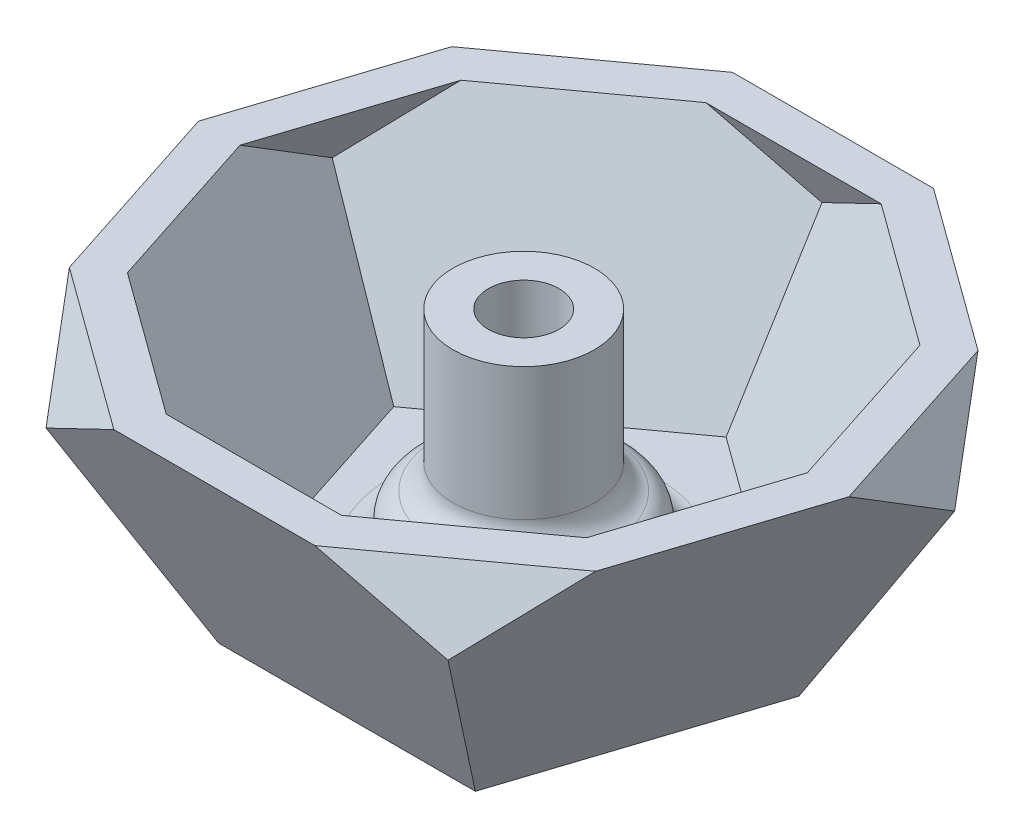
from build123d import *

# Parameters (mm, degrees)
BOSS_EXTRUDE1_DEPTH     = 30
BOSS_EXTRUDE1_TAPER     = -26.56505118
SKETCH3_OUTSIDE_W       = 108.076
SKETCH3_OUTSIDE_H       = 105.2
CUT_EXTRUDE1_DEPTH      = 30
CUT_EXTRUDE1_TAPER      = 26.56505118
SKETCH5_R               = 19.347524159
CUT_EXTRUDE2_DEPTH      = 25
SHELL1_T                = -2
SKETCH6_R               = 4
SKETCH6_R_2             = 2
BOSS_EXTRUDE2_DEPTH     = 13
SKETCH10_R              = 6
SKETCH10_R_2            = 4
BOSS_EXTRUDE4_DEPTH     = 3
FILLET5_R               = 1.5
CUT_EXTRUDE3_START      = -1
CUT_EXTRUDE3_DEPTH      = 2
CUT_EXTRUDE3_DEPTH_BACK = 2
FILLET6_R               = 1.5


with BuildPart() as part:
    # Sketch1 → Boss-Extrude1 (new body)
    with BuildSketch(Plane(origin=(0, 0, 0), x_dir=(1, 0, 0), z_dir=(0, 1, 0))):
        Polygon((0, 12.360679775), (-11.755705046, 3.819660113), (-7.26542528, -10), (7.26542528, -10), (11.755705046, 3.819660113), align=None)
    extrude(amount=BOSS_EXTRUDE1_DEPTH, taper=BOSS_EXTRUDE1_TAPER)

    # Sketch3 outside → Cut-Extrude1 (cut)
    with BuildSketch(Plane(origin=(0, 30, 0), x_dir=(1, 0, 0), z_dir=(0, 1, 0))):
        with Locations((0, 2.951)):
            Rectangle(SKETCH3_OUTSIDE_W, SKETCH3_OUTSIDE_H)
        Polygon((7.26542528, 10), (-7.26542528, 10), (-11.755705046, -3.819660113), (0, -12.360679775), (11.755705046, -3.819660113), align=None, mode=Mode.SUBTRACT)
    extrude(amount=-CUT_EXTRUDE1_DEPTH, taper=CUT_EXTRUDE1_TAPER, mode=Mode.SUBTRACT)

    # Sketch5 → Cut-Extrude2 (cut)
    with BuildSketch(Plane(origin=(0, 15, 0), x_dir=(1, 0, 0), z_dir=(0, 1, 0))):
        Circle(SKETCH5_R)
    extrude(amount=CUT_EXTRUDE2_DEPTH, mode=Mode.SUBTRACT)

    # Shell1
    shell1_openings = [part.faces().sort_by_distance(p)[0] for p in [
        (0, 15, 0),
    ]]
    offset(amount=SHELL1_T, openings=shell1_openings, kind=Kind.INTERSECTION)

    # Sketch6 → Boss-Extrude2 (add)
    with BuildSketch(Plane(origin=(0, 2, 0), x_dir=(1, 0, 0), z_dir=(0, 1, 0))):
        Circle(SKETCH6_R)
        Circle(SKETCH6_R_2, mode=Mode.SUBTRACT)
    extrude(amount=BOSS_EXTRUDE2_DEPTH)

    # Sketch12 → Loft1 section 0
    with BuildSketch(Plane(origin=(0, 3, 0), x_dir=(1, 0, 0), z_dir=(0, 1, 0))):
        Polygon((0, 11.450849719), (-10.890405242, 3.538507163), (-6.730640591, -9.263932023), (6.730640591, -9.263932023), (10.890405242, 3.538507163), align=None)
    # Sketch13 → Loft1 section 1
    with BuildSketch(Plane(origin=(0, 2, 0), x_dir=(1, 0, 0), z_dir=(0, 1, 0))):
        Polygon((10.30261999, 3.347524158), (0, 10.83281573), (-10.30261999, 3.347524158), (-6.367369327, -8.763932023), (6.367369327, -8.763932023), align=None)
    loft()

    # Sketch10 → Boss-Extrude4 (add)
    with BuildSketch(Plane(origin=(0, 3, 0), x_dir=(1, 0, 0), z_dir=(0, 1, 0))):
        Circle(SKETCH10_R)
        Circle(SKETCH10_R_2, mode=Mode.SUBTRACT)
    extrude(amount=BOSS_EXTRUDE4_DEPTH)

    # Fillet5
    fillet5_edges = [part.edges().sort_by_distance(p)[0] for p in [
        (-6, 3, 0),
        (-4, 6, 0),
    ]]
    fillet(fillet5_edges, radius=FILLET5_R)

    # Sketch10_3 → Cut-Extrude3 (cut, two sides)
    with BuildSketch(Plane(origin=(0, 3, 0), x_dir=(1, 0, 0), z_dir=(0, 1, 0)).offset(CUT_EXTRUDE3_START)) as cut_extrude3_sk:
        Polygon((0, 5.196152423), (-4.5, 2.598076211), (-4.5, -2.598076211), (0, -5.196152423), (4.5, -2.598076211), (4.5, 2.598076211), align=None)
    extrude(amount=CUT_EXTRUDE3_DEPTH, mode=Mode.SUBTRACT)
    extrude(cut_extrude3_sk.sketch, amount=-CUT_EXTRUDE3_DEPTH_BACK, mode=Mode.SUBTRACT)

    # Fillet6
    fillet6_edges = [part.edges().sort_by_distance(p)[0] for p in [
        (-6, 6, 0),
        (4.5, 4, 0),
        (2.25, 4, 3.897114317),
        (-2.25, 4, 3.897114317),
        (-4.5, 4, 0),
        (-2.25, 4, -3.897114317),
        (2.25, 4, -3.897114317),
    ]]
    fillet(fillet6_edges, radius=FILLET6_R)


solid = part.part
